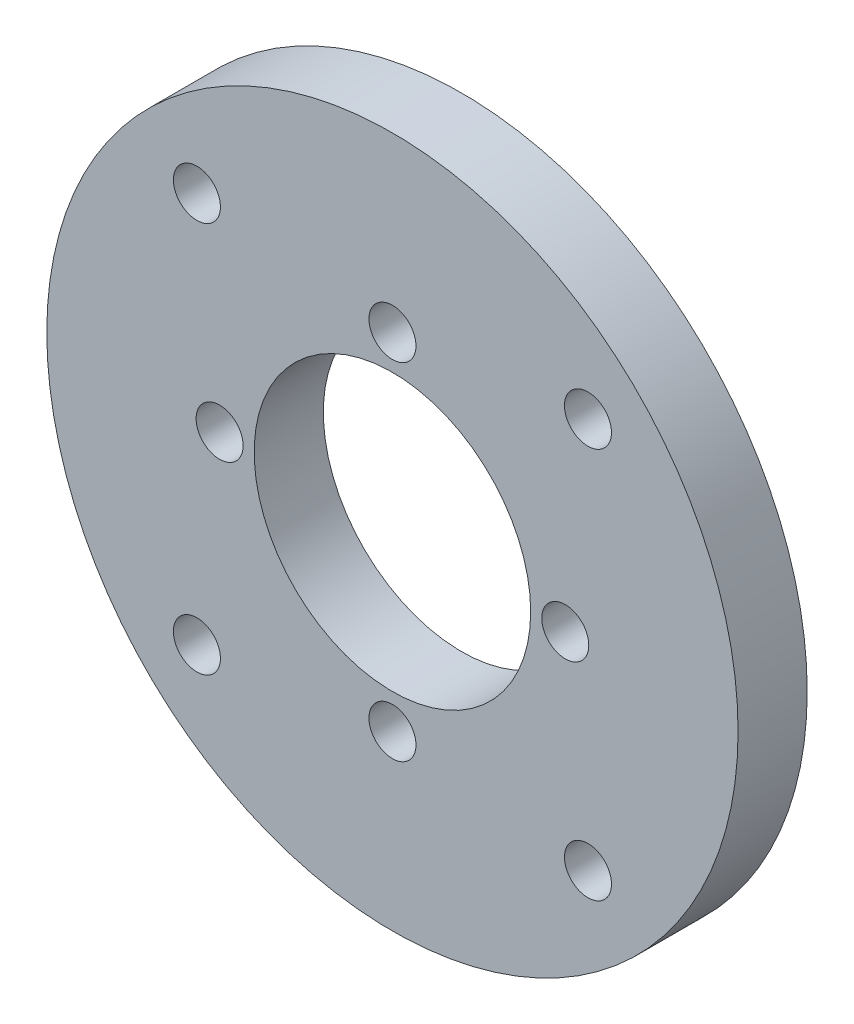
from build123d import *

# Parameters (mm, degrees)
SKETCH1_R           = 25
SKETCH1_R_2         = 10
BOSS_EXTRUDE1_DEPTH = 5
CIRPATTERN1_COUNT   = 4
CIRPATTERN2_COUNT   = 4


with BuildPart() as part:
    # Sketch1 → Boss-Extrude1 (new body)
    with BuildSketch(Plane.XY):
        Circle(SKETCH1_R)
        Circle(SKETCH1_R_2, mode=Mode.SUBTRACT)
    extrude(amount=BOSS_EXTRUDE1_DEPTH)

    # Sketch4 → M3 Clearance Hole1 (revolve, cut)
    with BuildSketch(Plane(origin=(0, 12.5, 5), x_dir=(0, -1, 0), z_dir=(1, 0, 0))):
        Polygon((0, 0), (0, 8.521463052), (1.7, 7.5), (1.7, 0), align=None)
    m3_clearance_hole1 = revolve(axis=Axis((0, 12.5, 11.35), (0, 0, -1)), mode=Mode.SUBTRACT)

    # CirPattern1: M3 Clearance Hole1 ×4 about axis
    cirpattern1_axis = Axis((0, 0, 0), (0, 0, 1))
    for i in range(1, CIRPATTERN1_COUNT):
        add(m3_clearance_hole1.rotate(cirpattern1_axis, i * 360 / CIRPATTERN1_COUNT), mode=Mode.SUBTRACT)

    # Sketch6 → M3 Clearance Hole2 (revolve, cut)
    with BuildSketch(Plane(origin=(14.142135624, 14.142135624, 5), x_dir=(0, -1, 0), z_dir=(1, 0, 0))):
        Polygon((0, 0), (0, 8.521463052), (1.7, 7.5), (1.7, 0), align=None)
    m3_clearance_hole2 = revolve(axis=Axis((14.142135624, 14.142135624, 11.35), (0, 0, -1)), mode=Mode.SUBTRACT)

    # CirPattern2: M3 Clearance Hole2 ×4 about axis
    cirpattern2_axis = Axis((0, 0, 0), (0, 0, 1))
    for i in range(1, CIRPATTERN2_COUNT):
        add(m3_clearance_hole2.rotate(cirpattern2_axis, i * 360 / CIRPATTERN2_COUNT), mode=Mode.SUBTRACT)


solid = part.part
